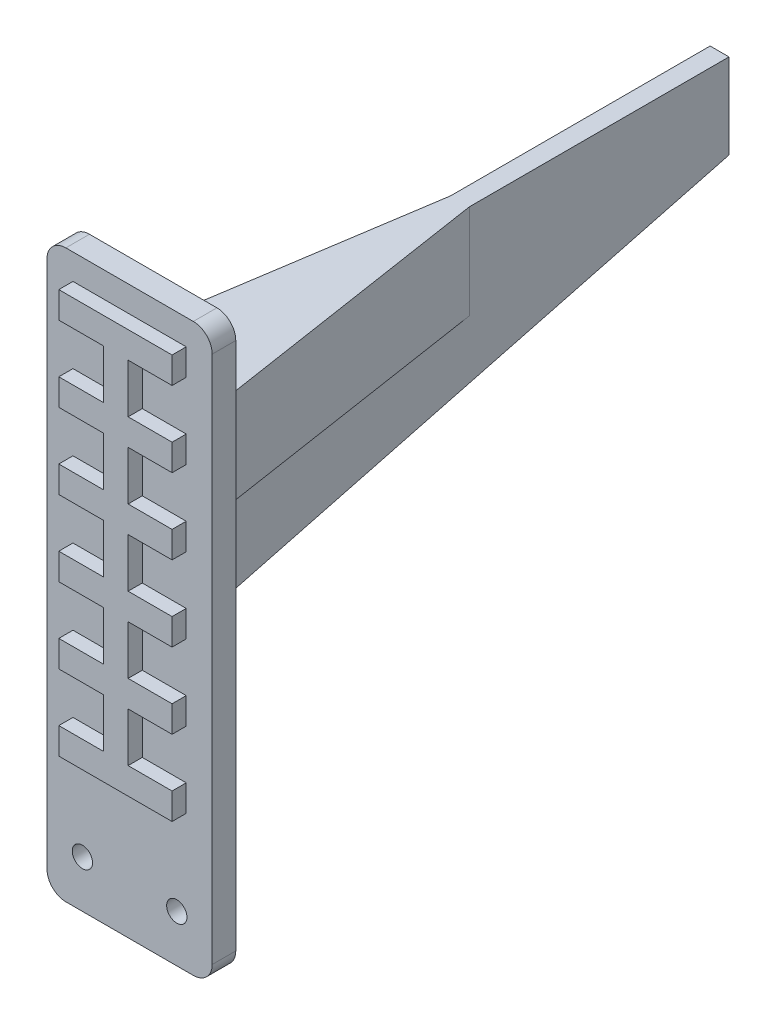
from build123d import *

# Parameters (mm, degrees)
SKETCH1_W           = 15
SKETCH1_H           = 100
SKETCH1_W_2         = 35
SKETCH1_H_2         = 20
BOSS_EXTRUDE1_DEPTH = 5
SKETCH3_R           = 2.15
CUT_EXTRUDE1_DEPTH  = 6
BOSS_EXTRUDE3_DEPTH = 5
BOSS_EXTRUDE4_DEPTH = 2
BOSS_EXTRUDE5_DEPTH = 5
BOSS_EXTRUDE6_DEPTH = 20
FILLET3_R           = 4
BOSS_EXTRUDE7_DEPTH = 3


with BuildPart() as part:
    # Sketch1 → Boss-Extrude1 (new body)
    with BuildSketch(Plane.XY):
        with Locations((17.5, 50)):
            Rectangle(SKETCH1_W, SKETCH1_H)
        with Locations((17.5, -10)):
            Rectangle(SKETCH1_W_2, SKETCH1_H_2)
    extrude(amount=BOSS_EXTRUDE1_DEPTH)

    # Sketch3 → Cut-Extrude1 (cut, through all)
    with BuildSketch(Plane(origin=(0, 0, 0), x_dir=(-1, 0, 0), z_dir=(0, 0, -1))):
        with Locations((-27.5, -10)):
            Circle(SKETCH3_R)
        with Locations((-7.5, -10)):
            Circle(SKETCH3_R)
    extrude(amount=-CUT_EXTRUDE1_DEPTH, mode=Mode.SUBTRACT)

    # Sketch4 → Boss-Extrude3 (add)
    with BuildSketch(Plane(origin=(0, 0, 0), x_dir=(-1, 0, 0), z_dir=(0, 0, -1))):
        Polygon((-35, 0), (-25, 0), (-25, 62), align=None)
        Polygon((-10, 62), (0, 0), (-10, 0), align=None)
    extrude(amount=-BOSS_EXTRUDE3_DEPTH)

    # Sketch5 → Boss-Extrude4 (add, symmetric)
    with BuildSketch(Plane.ZY.offset(-17.5)):
        Polygon((0, 80.291537197), (0, 31), (-120, 62.291537197), (-120, 80.291537197), align=None)
    extrude(amount=BOSS_EXTRUDE4_DEPTH, both=True)

    # Sketch6 → Boss-Extrude5 (add)
    with BuildSketch(Plane.XY.offset(5)):
        Polygon((35, 100), (35, 0), (25, 62), (25, 100), align=None)
        Polygon((10, 100), (0, 100), (0, 0), (10, 62), align=None)
    extrude(amount=-BOSS_EXTRUDE5_DEPTH)

    # Sketch7 → Boss-Extrude6 (add)
    with BuildSketch(Plane(origin=(0, 80.291537197, 0), x_dir=(1, 0, 0), z_dir=(0, 1, 0))):
        Polygon((15.5, 65), (15.5, 0), (5.5, 0), align=None)
        Polygon((19.5, 0), (29.5, 0), (19.5, 65), align=None)
    extrude(amount=-BOSS_EXTRUDE6_DEPTH)

    # Fillet3
    fillet3_edges = [part.edges().sort_by_distance(p)[0] for p in [
        (35, -20, 2.5),
        (0, -20, 2.5),
        (35, 100, 2.5),
        (0, 100, 2.5),
    ]]
    fillet(fillet3_edges, radius=FILLET3_R)

    # Sketch8 → Boss-Extrude7 (add)
    with BuildSketch(Plane.XY.offset(5)):
        Polygon((14.979978143, 14.595461976), (5.5, 14.595461976), (5.5, 8.99207654), (29.5, 8.99207654), (29.5, 14.595461976), (20.184726016, 14.595461976), (20.184726016, 24.99207654), (29.5, 24.99207654), (29.5, 30.595461976), (20.184726016, 30.595461976), (20.184726016, 40.99207654), (29.5, 40.99207654), (29.5, 46.595461976), (20.184726016, 46.595461976), (20.184726016, 56.99207654), (29.5, 56.99207654), (29.5, 62.595461976), (20.184726016, 62.595461976), (20.184726016, 72.99207654), (29.5, 72.99207654), (29.5, 78.595461976), (20.184726016, 78.595461976), (20.184726016, 88.99207654), (29.5, 88.99207654), (29.5, 94.595461976), (5.5, 94.595461976), (5.5, 88.99207654), (14.979978143, 88.99207654), (14.979978143, 78.595461976), (5.5, 78.595461976), (5.5, 72.99207654), (14.979978143, 72.99207654), (14.979978143, 62.595461976), (5.5, 62.595461976), (5.5, 56.99207654), (14.979978143, 56.99207654), (14.979978143, 46.595461976), (5.5, 46.595461976), (5.5, 40.99207654), (14.979978143, 40.99207654), (14.979978143, 30.595461976), (5.5, 30.595461976), (5.5, 24.99207654), (14.979978143, 24.99207654), align=None)
    extrude(amount=BOSS_EXTRUDE7_DEPTH)


solid = part.part
